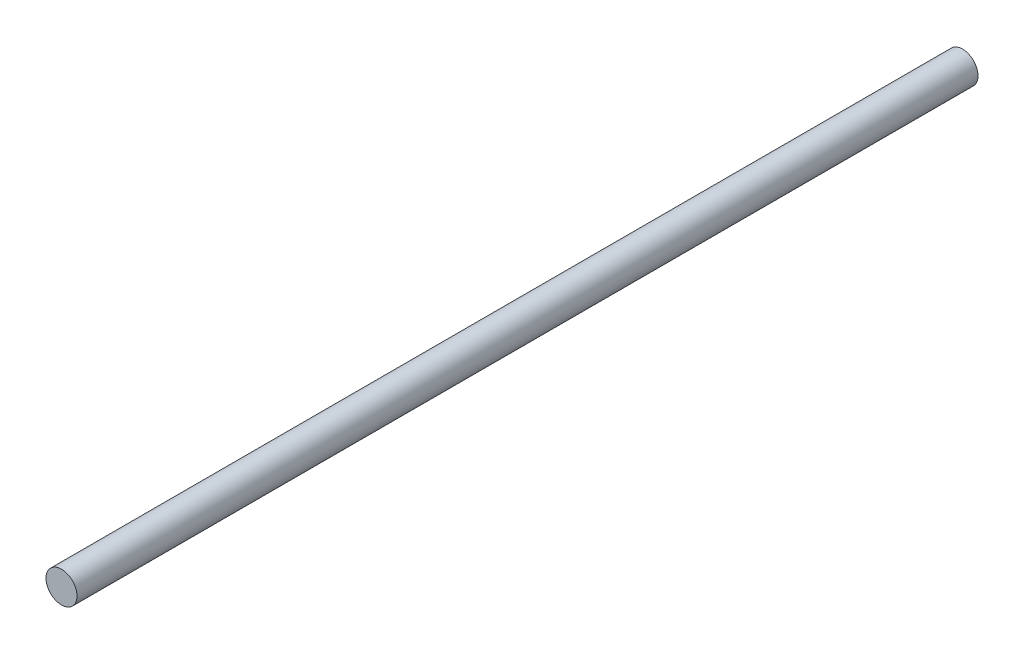
from build123d import *

# Parameters (mm, degrees)
SKETCH2_W = 232.347675392
SKETCH2_H = 4


with BuildPart() as part:
    # Sketch2 → Revolve1 (revolve)
    with BuildSketch(Plane(origin=(0, 0, 0), x_dir=(0, 0, -1), z_dir=(1, 0, 0))):
        with Locations((116.173837696, 2)):
            Rectangle(SKETCH2_W, SKETCH2_H)
    revolve(axis=Axis((0, 0, 0), (0, 0, 1)))


solid = part.part
